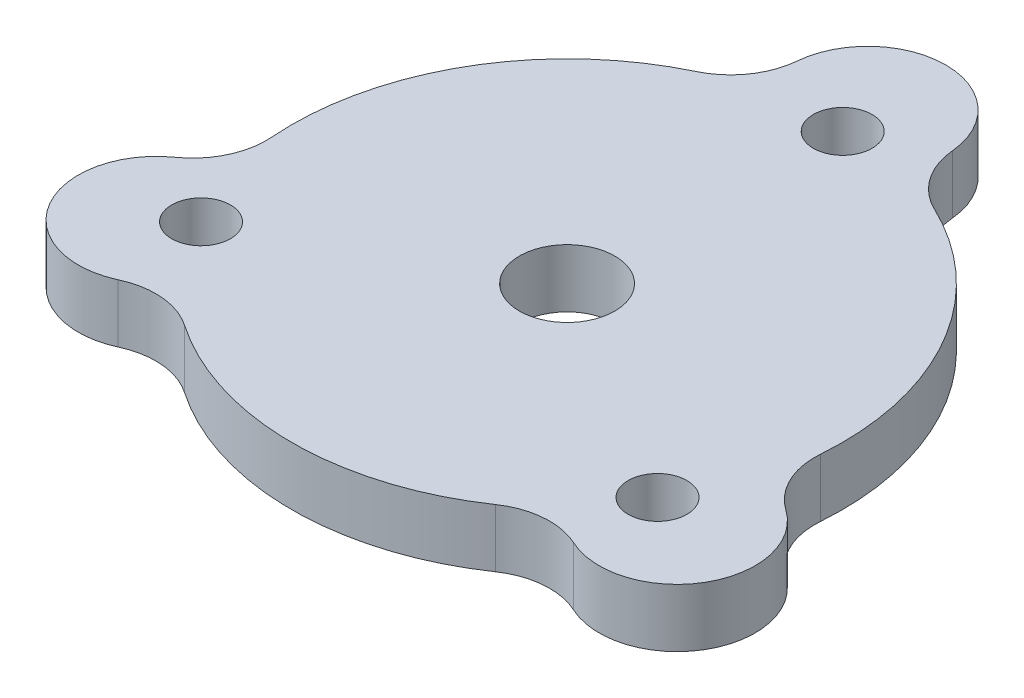
from build123d import *

# Parameters (mm, degrees)
SKETCH1_R           = 2.6
BOSS_EXTRUDE1_DEPTH = 3.175
FILLET1_R           = 4
SKETCH2_R           = 1.6
CUT_EXTRUDE1_DEPTH  = 4.1750001


with BuildPart() as part:
    # Sketch1 → Boss-Extrude1 (new body)
    with BuildSketch(Plane(origin=(0, 0, 0), x_dir=(1, 0, 0), z_dir=(0, 1, 0))):
        with BuildLine():
            Line((-4.25, 16.385322381), (-4.25, 14.385322381))
            ThreePointArc((-4.25, 14.385322381), (-12.990381057, 7.5), (-14.583054623, -3.512053224))
            Line((-14.583054623, -3.512053224), (-16.315105431, -4.512053224))
            ThreePointArc((-16.315105431, -4.512053224), (-17.870713397, -10.31766119), (-12.065105431, -11.873269156))
            Line((-12.065105431, -11.873269156), (-10.333054623, -10.873269156))
            ThreePointArc((-10.333054623, -10.873269156), (0, -15), (10.333054623, -10.873269156))
            Line((10.333054623, -10.873269156), (12.065105431, -11.873269156))
            ThreePointArc((12.065105431, -11.873269156), (17.870713397, -10.31766119), (16.315105431, -4.512053224))
            Line((16.315105431, -4.512053224), (14.583054623, -3.512053224))
            ThreePointArc((14.583054623, -3.512053224), (12.990381057, 7.5), (4.25, 14.385322381))
            Line((4.25, 14.385322381), (4.25, 16.385322381))
            ThreePointArc((4.25, 16.385322381), (0, 20.635322381), (-4.25, 16.385322381))
        make_face()
        Circle(SKETCH1_R, mode=Mode.SUBTRACT)
    extrude(amount=BOSS_EXTRUDE1_DEPTH)

    # Fillet1
    fillet1_edges = [part.edges().sort_by_distance(p)[0] for p in [
        (-14.583054623, 1.5875, 3.512053224),
        (-4.25, 1.5875, -14.385322381),
        (4.25, 1.5875, -14.385322381),
        (14.583054623, 1.5875, 3.512053224),
        (10.333054623, 1.5875, 10.873269156),
        (-10.333054623, 1.5875, 10.873269156),
    ]]
    fillet(fillet1_edges, radius=FILLET1_R)

    # Sketch2 → Cut-Extrude1 (cut, through all)
    with BuildSketch(Plane(origin=(0, 3.175, 0), x_dir=(1, 0, 0), z_dir=(0, 1, 0))):
        with Locations((-12.88502754, -7.05928361)):
            Circle(SKETCH2_R)
        with Locations((12.556032709, -7.629119373)):
            Circle(SKETCH2_R)
        with Locations((0.328994831, 14.688402983)):
            Circle(SKETCH2_R)
    extrude(amount=-CUT_EXTRUDE1_DEPTH, mode=Mode.SUBTRACT)


solid = part.part
